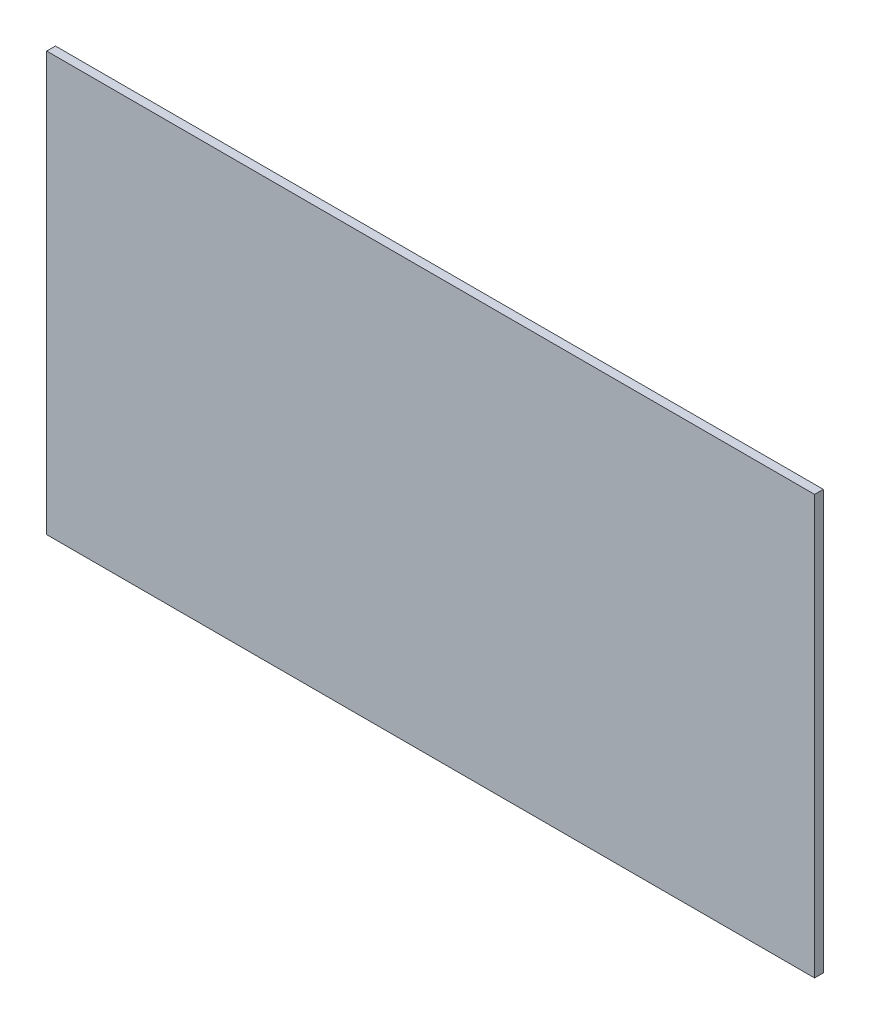
from build123d import *

# Parameters (mm, degrees)
SKETCH1_W           = 880
SKETCH1_H           = 480
BOSS_EXTRUDE1_DEPTH = 10


with BuildPart() as part:
    # Sketch1 → Boss-Extrude1 (new body)
    with BuildSketch(Plane.XY):
        Rectangle(SKETCH1_W, SKETCH1_H)
    extrude(amount=BOSS_EXTRUDE1_DEPTH)


solid = part.part
